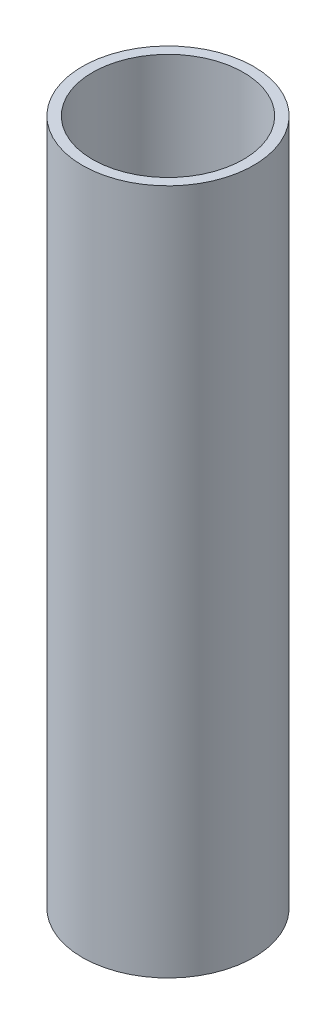
from build123d import *

# Parameters (mm, degrees)
SKETCH1_R           = 12.6873
SKETCH1_R_2         = 11.176
BOSS_EXTRUDE1_DEPTH = 101.6


with BuildPart() as part:
    # Sketch1 → Boss-Extrude1 (new body)
    with BuildSketch(Plane(origin=(0, 0, 0), x_dir=(1, 0, 0), z_dir=(0, 1, 0))):
        Circle(SKETCH1_R)
        Circle(SKETCH1_R_2, mode=Mode.SUBTRACT)
    extrude(amount=BOSS_EXTRUDE1_DEPTH)


solid = part.part
